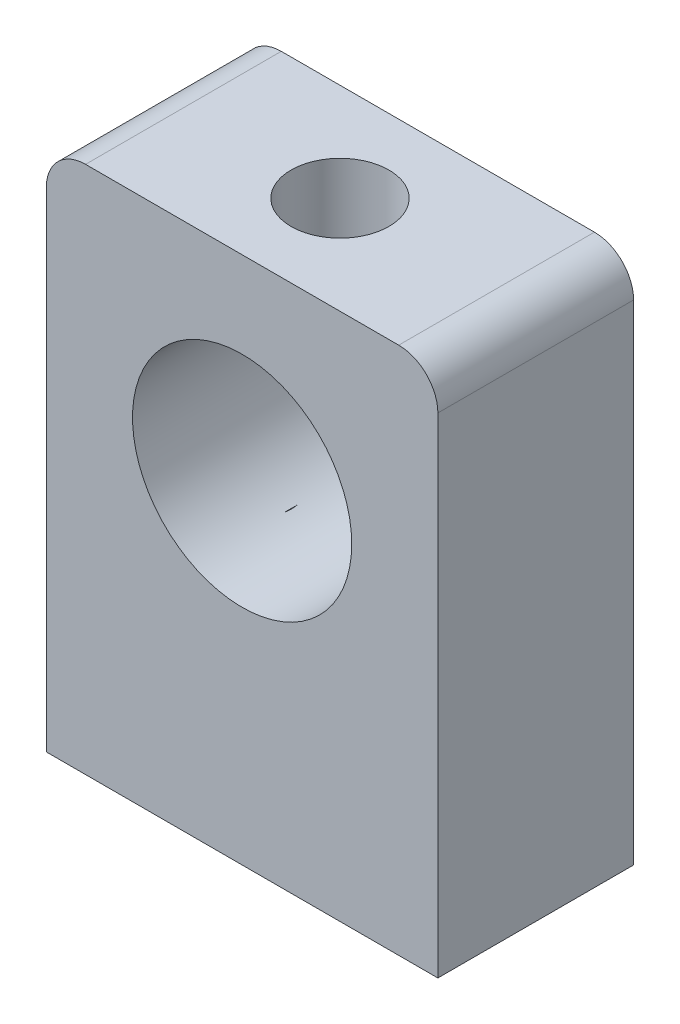
from build123d import *

# Parameters (mm, degrees)
SKETCH_1_R          = 5.6
EXTRUDE_1_DEPTH     = 10
SKETCH_9_R          = 2.5
CUT_EXTRUDE_1_DEPTH = 6
SKETCH_11_R         = 2.5
CUT_EXTRUDE_2_DEPTH = 12


with BuildPart() as part:
    # 草图1 → 凸台-拉伸1 (new body)
    with BuildSketch(Plane.XY):
        with BuildLine():
            Line((-9.061643836, 9.77739726), (6.938356164, 9.77739726))
            ThreePointArc((6.938356164, 9.77739726), (8.352569727, 9.191610823), (8.938356164, 7.77739726))
            Line((8.938356164, 7.77739726), (8.938356164, -17.22260274))
            Line((8.938356164, -17.22260274), (-11.061643836, -17.22260274))
            Line((-11.061643836, -17.22260274), (-11.061643836, 7.77739726))
            ThreePointArc((-11.061643836, 7.77739726), (-10.475857398, 9.191610823), (-9.061643836, 9.77739726))
        make_face()
        with Locations((-1.061643836, -0.22260274)):
            Circle(SKETCH_1_R, mode=Mode.SUBTRACT)
    extrude(amount=EXTRUDE_1_DEPTH)

    # 草图9 → 切除-拉伸1 (cut)
    with BuildSketch(Plane(origin=(0, 9.77739726, 0), x_dir=(1, 0, 0), z_dir=(0, 1, 0))):
        with Locations((-1.061643836, -5)):
            Circle(SKETCH_9_R)
    extrude(amount=-CUT_EXTRUDE_1_DEPTH, mode=Mode.SUBTRACT)

    # 草图11 → 切除-拉伸2 (cut)
    with BuildSketch(Plane.XZ.offset(17.22260274)):
        with Locations((-6.061643836, 5)):
            Circle(SKETCH_11_R)
        with Locations((3.938356164, 5)):
            Circle(SKETCH_11_R)
    extrude(amount=-CUT_EXTRUDE_2_DEPTH, mode=Mode.SUBTRACT)


solid = part.part
